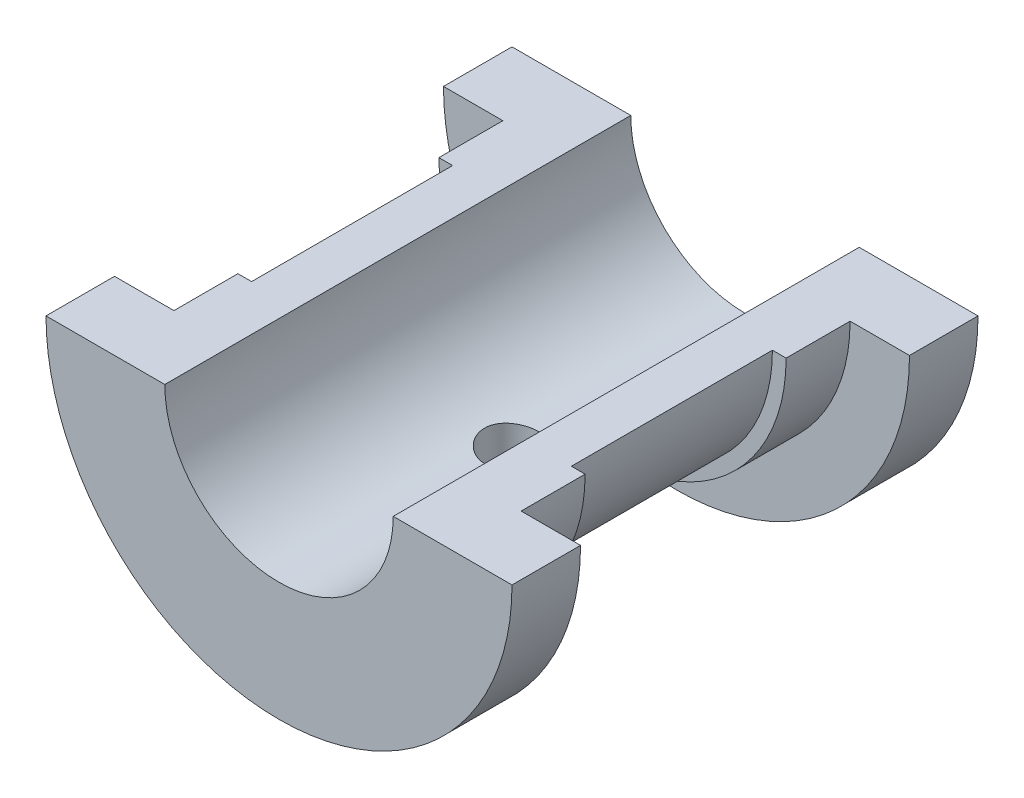
from build123d import *

# Parameters (mm, degrees)
REVOLVE1_ANGLE     = 180
SKETCH2_R          = 3
CUT_EXTRUDE1_DEPTH = 18.5


with BuildPart() as part:
    # Sketch1 → Revolve1 (revolve)
    with BuildSketch(Plane(origin=(0, 0, 0), x_dir=(1, 0, 0), z_dir=(0, 1, 0))):
        Polygon((-25.5, 25.5), (-25.5, 18), (-19, 18), (-19, 11), (-17.5, 11), (-17.5, -11), (-19, -11), (-19, -18), (-25.5, -18), (-25.5, -25.5), (-12.5, -25.5), (-12.5, 25.5), align=None)
    revolve(axis=Axis((0, 0, 0), (0, 0, 1)), revolution_arc=REVOLVE1_ANGLE)

    # Sketch2 → Cut-Extrude1 (cut, through all)
    with BuildSketch(Plane(origin=(0, -17.5, 0), x_dir=(-1, 0, 0), z_dir=(0, -1, 0))):
        with Locations(Location((0, 0, 0), (0, 0, 90))):  # turned: the seam where the file's is
            Circle(SKETCH2_R)
    extrude(amount=-CUT_EXTRUDE1_DEPTH, mode=Mode.SUBTRACT)


solid = part.part
